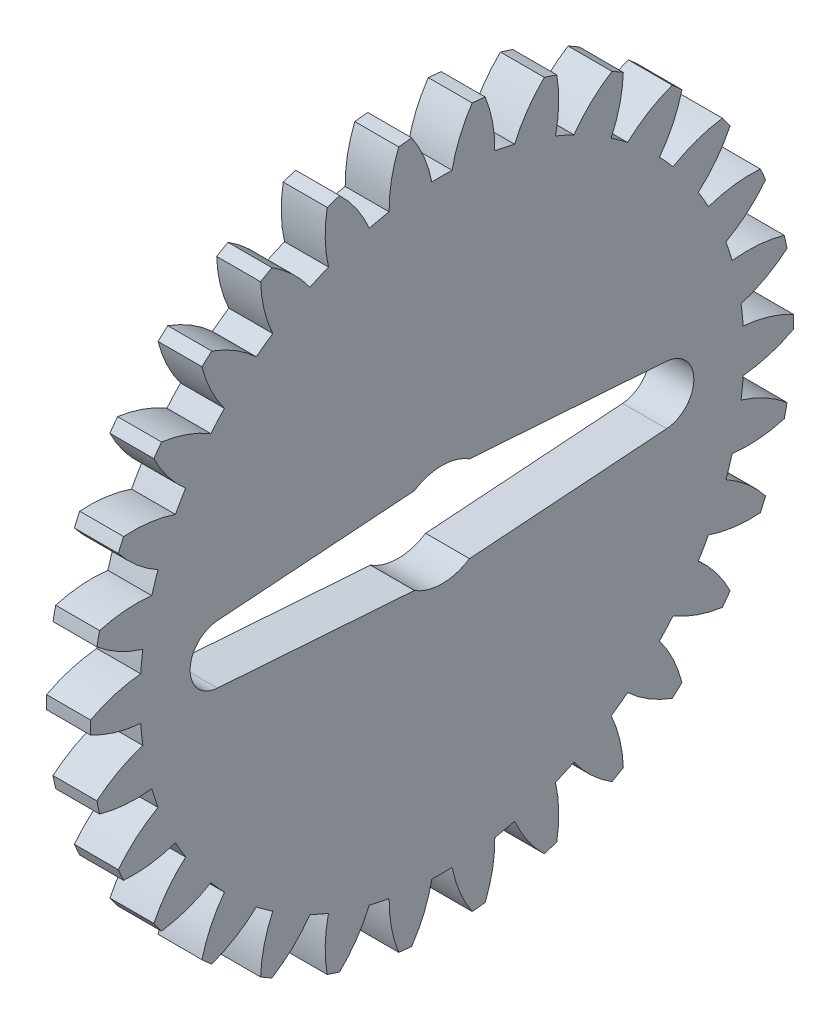
from build123d import *

# Parameters (mm, degrees)
BASPROSKE_W        = 3
BASPROSKE_H        = 24
TOOTHCUT_DEPTH     = 35.073450075
TEETHCUTS_COUNT    = 30
TEETHCUTS_ANGLE    = 348
BORSKE_R           = 2
BORE_DEPTH         = 50.001016
CUT_EXTRUDE1_DEPTH = 35.010864624


with BuildPart() as part:
    # BasProSke → Base-Revolve (revolve)
    with BuildSketch(Plane(origin=(0, 0, 0), x_dir=(1, 0, 0), z_dir=(0, 1, 0)), mode=Mode.PRIVATE) as base_revolve_sk:
        with Locations((1.5, 12)):
            Rectangle(BASPROSKE_W, BASPROSKE_H)
    revolve(base_revolve_sk.sketch.rotate(Axis((-10, 0, 0), (1, 0, 0)), 180), axis=Axis((-10, 0, 0), (1, 0, 0)))

    # TooCutSke → ToothCut (cut, through all)
    with BuildSketch(Plane(origin=(0, 0, 0), x_dir=(0, 0, -1), z_dir=(1, 0, 0))):
        with BuildLine():
            ThreePointArc((0.693278797, 20.612344372), (0, 20.624), (-0.693278797, 20.612344372))
            ThreePointArc((-0.693278797, 20.612344372), (-1.270739341, 22.465148834), (-2.231973449, 24.151083009))
            ThreePointArc((-2.231973449, 24.151083009), (0, 24.254), (2.231973449, 24.151083009))
            ThreePointArc((2.231973449, 24.151083009), (1.270739341, 22.465148834), (0.693278797, 20.612344372))
        make_face()
    toothcut = extrude(amount=TOOTHCUT_DEPTH, mode=Mode.SUBTRACT)

    # TeethCuts: ToothCut ×30 about axis
    teethcuts_axis = Axis((-10, 0, 0), (1, 0, 0))
    for i in range(1, TEETHCUTS_COUNT):
        add(toothcut.rotate(teethcuts_axis, i * TEETHCUTS_ANGLE / (TEETHCUTS_COUNT - 1)), mode=Mode.SUBTRACT)

    # BorSke → Bore (cut, symmetric)
    with BuildSketch(Plane(origin=(0, 0, 0), x_dir=(0, 0, -1), z_dir=(1, 0, 0))):
        with Locations(Location((0, 0, 0), (0, 0, 180))):
            Circle(BORSKE_R)
    extrude(amount=BORE_DEPTH, both=True, mode=Mode.SUBTRACT)

    # Sketch2 → Cut-Extrude1 (cut, through all)
    with BuildSketch(Plane.ZY):
        with BuildLine():
            Line((-1.88348082, 2.95), (-15.34156858, 1.994983292))
            ThreePointArc((-15.34156858, 1.994983292), (-17.2, 0), (-15.34156858, -1.994983292))
            Line((-15.34156858, -1.994983292), (-1.88348082, -2.95))
            ThreePointArc((-1.88348082, -2.95), (0, -3.5), (1.88348082, -2.95))
            Line((1.88348082, -2.95), (15.34156858, -1.994983292))
            ThreePointArc((15.34156858, -1.994983292), (17.2, 0), (15.34156858, 1.994983292))
            Line((15.34156858, 1.994983292), (1.88348082, 2.95))
            ThreePointArc((1.88348082, 2.95), (0, 3.5), (-1.88348082, 2.95))
        make_face()
    extrude(amount=-CUT_EXTRUDE1_DEPTH, mode=Mode.SUBTRACT)


solid = part.part
